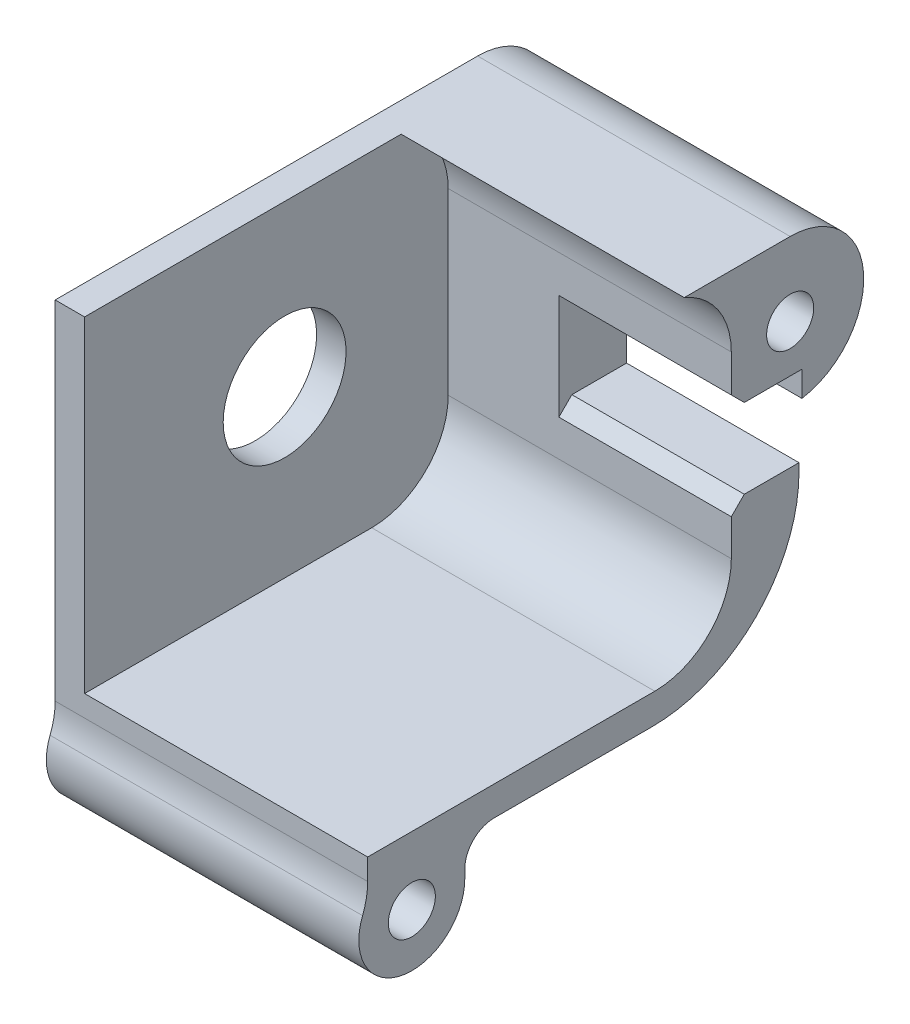
from build123d import *

# Parameters (mm, degrees)
BOSS_EXTRUDE1_START = -0.2
SKETCH1_R           = 1.6
BOSS_EXTRUDE1_DEPTH = 7.520002
BOSS_EXTRUDE2_START = -0.2
SKETCH1_7_R         = 1.6
SKETCH1_7_R_2       = 1.995
SKETCH1_7_R_3       = 4.175
SKETCH1_7_R_4       = 1.845
BOSS_EXTRUDE2_DEPTH = 2
BOSS_EXTRUDE3_START = 7.320002
SKETCH1_8_R         = 1.6
BOSS_EXTRUDE3_DEPTH = 11.720001513


with BuildPart() as part:
    # Sketch1 → Boss-Extrude1 (new body)
    with BuildSketch(Plane(origin=(-6551.301651172, 0, 0), x_dir=(0, 0, -1), z_dir=(1, 0, 0)).offset(BOSS_EXTRUDE1_START)):
        with BuildLine():
            Line((783.267150495, -3133.594839225), (763.752150495, -3133.594839225))
            Line((763.752150495, -3133.594839225), (763.752150495, -3135.038892457))
            ThreePointArc((763.752150495, -3135.038892457), (763.664167085, -3135.972751667), (763.403313286, -3136.873745229))
            ThreePointArc((763.403313286, -3136.873745229), (766.079771865, -3141.73149117), (770.352150495, -3138.194839225))
            Line((770.352150495, -3138.194839225), (770.352150495, -3137.594839225))
            ThreePointArc((770.352150495, -3137.594839225), (770.937936933, -3136.180625663), (772.352150495, -3135.594839225))
            Line((772.352150495, -3135.594839225), (783.067150495, -3135.594839225))
            ThreePointArc((783.067150495, -3135.594839225), (790.138218307, -3132.665907037), (793.067150495, -3125.594839225))
            Line((793.067150495, -3125.594839225), (793.067150495, -3121.390787525))
            ThreePointArc((793.067150495, -3121.390787525), (797.458109686, -3116.126374636), (792.467150495, -3111.426918067))
            Line((792.467150495, -3111.426918067), (785.267150495, -3111.426918067))
            ThreePointArc((785.267150495, -3111.426918067), (787.593812026, -3113.342477046), (788.467150495, -3116.226918067))
            Line((788.467150495, -3116.226918067), (788.467150495, -3128.394839225))
            ThreePointArc((788.467150495, -3128.394839225), (786.944105758, -3132.071794487), (783.267150495, -3133.594839225))
        make_face()
        with Locations(Location((766.752150495, -3138.194839225, 0), (0, 0, 180))):
            Circle(SKETCH1_R, mode=Mode.SUBTRACT)
        with Locations(Location((792.467150495, -3116.426918067, 0), (0, 0, 180))):
            Circle(SKETCH1_R, mode=Mode.SUBTRACT)
    extrude(amount=BOSS_EXTRUDE1_DEPTH)

    # Sketch1_7 → Boss-Extrude2 (add)
    with BuildSketch(Plane(origin=(-6551.301651172, 0, 0), x_dir=(0, 0, -1), z_dir=(1, 0, 0)).offset(BOSS_EXTRUDE2_START)):
        with BuildLine():
            Line((792.467150495, -3111.426918067), (785.267150495, -3111.426918067))
            ThreePointArc((785.267150495, -3111.426918067), (786.906779124, -3112.513011303), (788.025771185, -3114.130366343))
            ThreePointArc((788.025771185, -3114.130366343), (789.867415761, -3112.155925289), (792.467150495, -3111.426918067))
        make_face()
        with BuildLine():
            ThreePointArc((797.467150495, -3116.426918067), (796.002684401, -3112.891384161), (792.467150495, -3111.426918067))
            ThreePointArc((792.467150495, -3111.426918067), (789.867415761, -3112.155925289), (788.025771185, -3114.130366343))
            ThreePointArc((788.025771185, -3114.130366343), (788.355609377, -3115.155663565), (788.467150495, -3116.226918067))
            Line((788.467150495, -3116.226918067), (788.467150495, -3118.759075354))
            Line((788.467150495, -3118.759075354), (789.349993208, -3119.641918067))
            Line((789.349993208, -3119.641918067), (793.267150495, -3119.641918067))
            Line((793.267150495, -3119.641918067), (793.267150495, -3121.362503138))
            ThreePointArc((793.267150495, -3121.362503138), (796.275037048, -3119.667288416), (797.467150495, -3116.426918067))
        make_face()
        with Locations(Location((792.467150495, -3116.426918067, 0), (0, 0, 180))):
            Circle(SKETCH1_7_R, mode=Mode.SUBTRACT)
        with BuildLine():
            ThreePointArc((788.025771185, -3114.130366343), (787.802673468, -3114.626180978), (787.634729413, -3115.143287871))
            ThreePointArc((787.634729413, -3115.143287871), (787.733922547, -3115.681072451), (787.767150495, -3116.226918067))
            Line((787.767150495, -3116.226918067), (787.767150495, -3118.132790278))
            ThreePointArc((787.767150495, -3118.132790278), (788.069288323, -3118.805743053), (788.467150495, -3119.426918067))
            Line((788.467150495, -3119.426918067), (788.467150495, -3118.759075354))
            Line((788.467150495, -3118.759075354), (788.467150495, -3116.226918067))
            ThreePointArc((788.467150495, -3116.226918067), (788.355609377, -3115.155663565), (788.025771185, -3114.130366343))
        make_face()
        with BuildLine():
            Line((788.467150495, -3118.759075354), (788.467150495, -3119.426918067))
            ThreePointArc((788.467150495, -3119.426918067), (790.503939908, -3121.025374785), (793.067150495, -3121.390787525))
            ThreePointArc((793.067150495, -3121.390787525), (793.167293339, -3121.377655385), (793.267150495, -3121.362503138))
            Line((793.267150495, -3121.362503138), (793.267150495, -3119.641918067))
            Line((793.267150495, -3119.641918067), (789.349993208, -3119.641918067))
            Line((789.349993208, -3119.641918067), (788.467150495, -3118.759075354))
        make_face()
        with BuildLine():
            Line((788.467150495, -3119.426918067), (788.467150495, -3125.924760779))
            Line((788.467150495, -3125.924760779), (789.349993208, -3125.041918067))
            Line((789.349993208, -3125.041918067), (793.067150495, -3125.041918067))
            Line((793.067150495, -3125.041918067), (793.067150495, -3121.390787525))
            ThreePointArc((793.067150495, -3121.390787525), (790.503939908, -3121.025374785), (788.467150495, -3119.426918067))
        make_face()
        with BuildLine():
            Line((783.267150495, -3133.594839225), (763.752150495, -3133.594839225))
            Line((763.752150495, -3133.594839225), (763.752150495, -3135.038892457))
            ThreePointArc((763.752150495, -3135.038892457), (763.664167085, -3135.972751667), (763.403313286, -3136.873745229))
            ThreePointArc((763.403313286, -3136.873745229), (766.079771865, -3141.73149117), (770.352150495, -3138.194839225))
            Line((770.352150495, -3138.194839225), (770.352150495, -3137.594839225))
            ThreePointArc((770.352150495, -3137.594839225), (770.937936933, -3136.180625663), (772.352150495, -3135.594839225))
            Line((772.352150495, -3135.594839225), (783.067150495, -3135.594839225))
            ThreePointArc((783.067150495, -3135.594839225), (790.138218307, -3132.665907037), (793.067150495, -3125.594839225))
            Line((793.067150495, -3125.594839225), (793.067150495, -3125.041918067))
            Line((793.067150495, -3125.041918067), (789.349993208, -3125.041918067))
            Line((789.349993208, -3125.041918067), (788.467150495, -3125.924760779))
            Line((788.467150495, -3125.924760779), (788.467150495, -3128.394839225))
            ThreePointArc((788.467150495, -3128.394839225), (786.944105758, -3132.071794487), (783.267150495, -3133.594839225))
        make_face()
        with Locations(Location((766.752150495, -3138.194839225, 0), (0, 0, 180))):
            Circle(SKETCH1_7_R, mode=Mode.SUBTRACT)
        with BuildLine():
            Line((763.752150495, -3111.726918067), (763.752150495, -3132.894839225))
            Line((763.752150495, -3132.894839225), (783.267150495, -3132.894839225))
            ThreePointArc((783.267150495, -3132.894839225), (786.449131011, -3131.57681974), (787.767150495, -3128.394839225))
            Line((787.767150495, -3128.394839225), (787.767150495, -3118.132790278))
            ThreePointArc((787.767150495, -3118.132790278), (787.472048486, -3116.648177904), (787.634729413, -3115.143287871))
            ThreePointArc((787.634729413, -3115.143287871), (786.039664167, -3112.682462123), (783.267150495, -3111.726918067))
            Line((783.267150495, -3111.726918067), (763.752150495, -3111.726918067))
        make_face()
        with Locations((766.097150495, -3122.341918067)):
            Circle(SKETCH1_7_R_2, mode=Mode.SUBTRACT)
        with Locations(Location((777.347150495, -3122.341918067, 0), (0, 0, 180))):
            Circle(SKETCH1_7_R_3, mode=Mode.SUBTRACT)
        with BuildLine():
            Line((763.752150495, -3132.894839225), (763.752150495, -3133.594839225))
            Line((763.752150495, -3133.594839225), (783.267150495, -3133.594839225))
            ThreePointArc((783.267150495, -3133.594839225), (786.944105758, -3132.071794487), (788.467150495, -3128.394839225))
            Line((788.467150495, -3128.394839225), (788.467150495, -3125.924760779))
            Line((788.467150495, -3125.924760779), (788.467150495, -3119.426918067))
            ThreePointArc((788.467150495, -3119.426918067), (788.069288323, -3118.805743053), (787.767150495, -3118.132790278))
            Line((787.767150495, -3118.132790278), (787.767150495, -3128.394839225))
            ThreePointArc((787.767150495, -3128.394839225), (786.449131011, -3131.57681974), (783.267150495, -3132.894839225))
            Line((783.267150495, -3132.894839225), (763.752150495, -3132.894839225))
        make_face()
        with BuildLine():
            Line((763.752150495, -3111.426918067), (763.752150495, -3111.726918067))
            Line((763.752150495, -3111.726918067), (783.267150495, -3111.726918067))
            ThreePointArc((783.267150495, -3111.726918067), (786.039664167, -3112.682462123), (787.634729413, -3115.143287871))
            ThreePointArc((787.634729413, -3115.143287871), (787.802673468, -3114.626180978), (788.025771185, -3114.130366343))
            ThreePointArc((788.025771185, -3114.130366343), (786.906779124, -3112.513011303), (785.267150495, -3111.426918067))
            Line((785.267150495, -3111.426918067), (763.752150495, -3111.426918067))
        make_face()
        with BuildLine():
            ThreePointArc((787.767150495, -3116.226918067), (787.733922547, -3115.681072451), (787.634729413, -3115.143287871))
            ThreePointArc((787.634729413, -3115.143287871), (787.472048486, -3116.648177904), (787.767150495, -3118.132790278))
            Line((787.767150495, -3118.132790278), (787.767150495, -3116.226918067))
        make_face()
        with Locations((766.097150495, -3122.341918067)):
            Circle(SKETCH1_7_R_2)
        with Locations((766.097150495, -3122.341918067)):
            Circle(SKETCH1_7_R_4, mode=Mode.SUBTRACT)
        with Locations((766.097150495, -3122.341918067)):
            Circle(SKETCH1_7_R_4)
    extrude(amount=-BOSS_EXTRUDE2_DEPTH)

    # Sketch1_8 → Boss-Extrude3 (add)
    with BuildSketch(Plane(origin=(-6551.301651172, 0, 0), x_dir=(0, 0, -1), z_dir=(1, 0, 0)).offset(BOSS_EXTRUDE3_START)):
        with BuildLine():
            Line((783.267150495, -3133.594839225), (763.752150495, -3133.594839225))
            Line((763.752150495, -3133.594839225), (763.752150495, -3135.038892457))
            ThreePointArc((763.752150495, -3135.038892457), (763.664167085, -3135.972751667), (763.403313286, -3136.873745229))
            ThreePointArc((763.403313286, -3136.873745229), (766.079771865, -3141.73149117), (770.352150495, -3138.194839225))
            Line((770.352150495, -3138.194839225), (770.352150495, -3137.594839225))
            ThreePointArc((770.352150495, -3137.594839225), (770.937936933, -3136.180625663), (772.352150495, -3135.594839225))
            Line((772.352150495, -3135.594839225), (783.067150495, -3135.594839225))
            ThreePointArc((783.067150495, -3135.594839225), (790.138218307, -3132.665907037), (793.067150495, -3125.594839225))
            Line((793.067150495, -3125.594839225), (793.067150495, -3125.041918067))
            Line((793.067150495, -3125.041918067), (789.349993208, -3125.041918067))
            Line((789.349993208, -3125.041918067), (788.467150495, -3125.924760779))
            Line((788.467150495, -3125.924760779), (788.467150495, -3128.394839225))
            ThreePointArc((788.467150495, -3128.394839225), (786.944105758, -3132.071794487), (783.267150495, -3133.594839225))
        make_face()
        with Locations((766.752150495, -3138.194839225)):
            Circle(SKETCH1_8_R, mode=Mode.SUBTRACT)
        with BuildLine():
            Line((792.467150495, -3111.426918067), (785.267150495, -3111.426918067))
            ThreePointArc((785.267150495, -3111.426918067), (787.593812026, -3113.342477046), (788.467150495, -3116.226918067))
            Line((788.467150495, -3116.226918067), (788.467150495, -3118.759075354))
            Line((788.467150495, -3118.759075354), (789.349993208, -3119.641918067))
            Line((789.349993208, -3119.641918067), (793.267150495, -3119.641918067))
            Line((793.267150495, -3119.641918067), (793.267150495, -3121.362503138))
            ThreePointArc((793.267150495, -3121.362503138), (797.451020747, -3116.025623511), (792.467150495, -3111.426918067))
        make_face()
        with Locations((792.467150495, -3116.426918067)):
            Circle(SKETCH1_8_R, mode=Mode.SUBTRACT)
    extrude(amount=BOSS_EXTRUDE3_DEPTH)


solid = part.part
